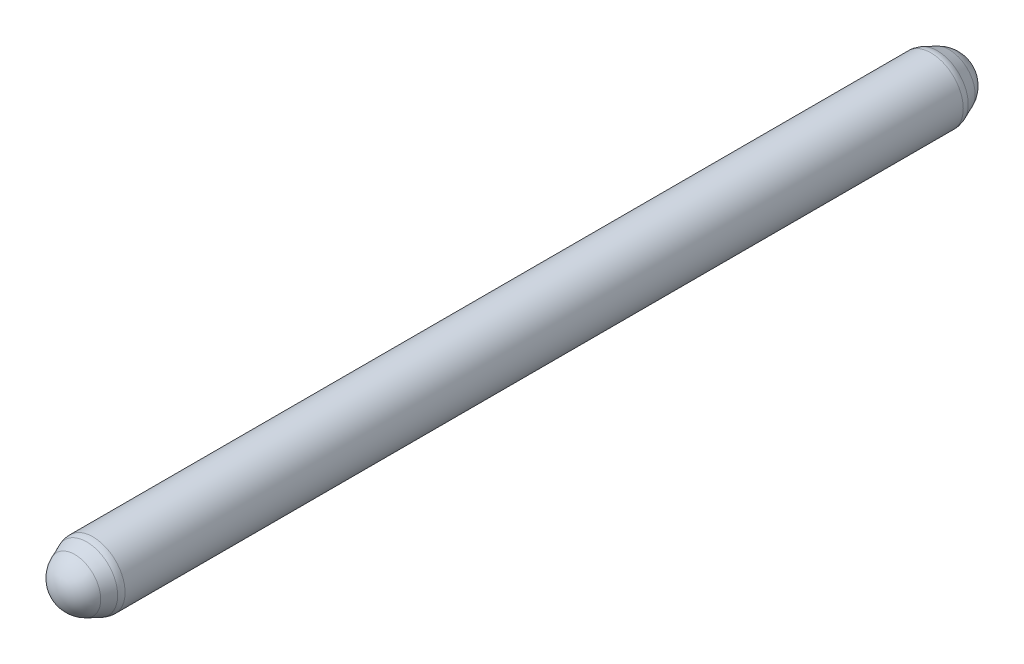
from build123d import *

# Parameters (mm, degrees)
SKETCH1_R           = 20
BOSS_EXTRUDE1_DEPTH = 262.5
FILLET1_R           = 10


with BuildPart() as part:
    # Sketch1 → Boss-Extrude1 (new body, symmetric)
    with BuildSketch(Plane.XY):
        Circle(SKETCH1_R)
    extrude(amount=BOSS_EXTRUDE1_DEPTH, both=True)

    # Sketch2 → Revolve1 (revolve)
    with BuildSketch(Plane(origin=(0, 0, 0), x_dir=(0, 0, -1), z_dir=(1, 0, 0))):
        with BuildLine():
            Line((-262.5, 20), (-262.5, 0))
            Line((-262.5, 0), (-282.5, 0))
            ThreePointArc((-282.5, 0), (-279.57043003, 9.686707526), (-271.763715382, 16.126419422))
            Line((-271.763715382, 16.126419422), (-262.5, 20))
        make_face()
    revolve1 = revolve(axis=Axis((0, 0, 262.5), (0, 0, 1)))

    # Mirror1: Revolve1 across plane
    add(revolve1.mirror(Plane.XY))

    # Fillet1
    fillet1_edges = [part.edges().sort_by_distance(p)[0] for p in [
        (14.142135624, 14.142135624, 262.5),
        (-14.142135624, -14.142135624, -262.5),
    ]]
    fillet(fillet1_edges, radius=FILLET1_R)


solid = part.part
